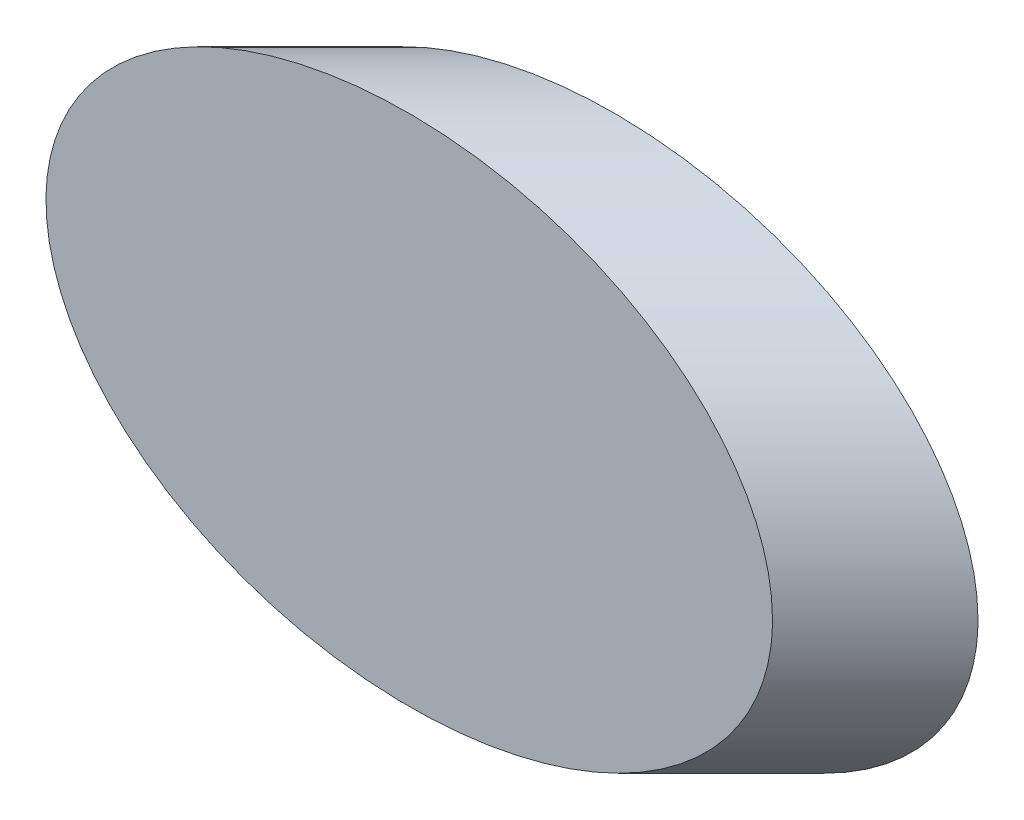
from build123d import *

# Parameters (mm, degrees)
SKETCH2_R               = 50
BOSS_EXTRUDE1_DEPTH     = 10
CUT_EXTRUDE1_DEPTH      = 72.414284285
CUT_EXTRUDE1_DEPTH_BACK = 72.414284285
SKETCH3_R               = 75
SKETCH3_R_2             = 25


with BuildPart() as part:
    # Sketch2 → Boss-Extrude1 (new body)
    with BuildSketch(Plane.XY):
        Circle(SKETCH2_R)
    extrude(amount=-BOSS_EXTRUDE1_DEPTH)

    # Sketch3 → Cut-Extrude1 (cut, two sides: drawn at the far end of the back side and taken through both)
    with BuildSketch(Plane(origin=(0, 0, 0), x_dir=(0.7071067811865464, 0, 0.7071067811865488), z_dir=(-0.7071067811865488, 0, 0.7071067811865464)).offset(-CUT_EXTRUDE1_DEPTH_BACK)):
        Circle(SKETCH3_R)
        Circle(SKETCH3_R_2, mode=Mode.SUBTRACT)
    extrude(amount=CUT_EXTRUDE1_DEPTH + CUT_EXTRUDE1_DEPTH_BACK, mode=Mode.SUBTRACT)


solid = part.part
